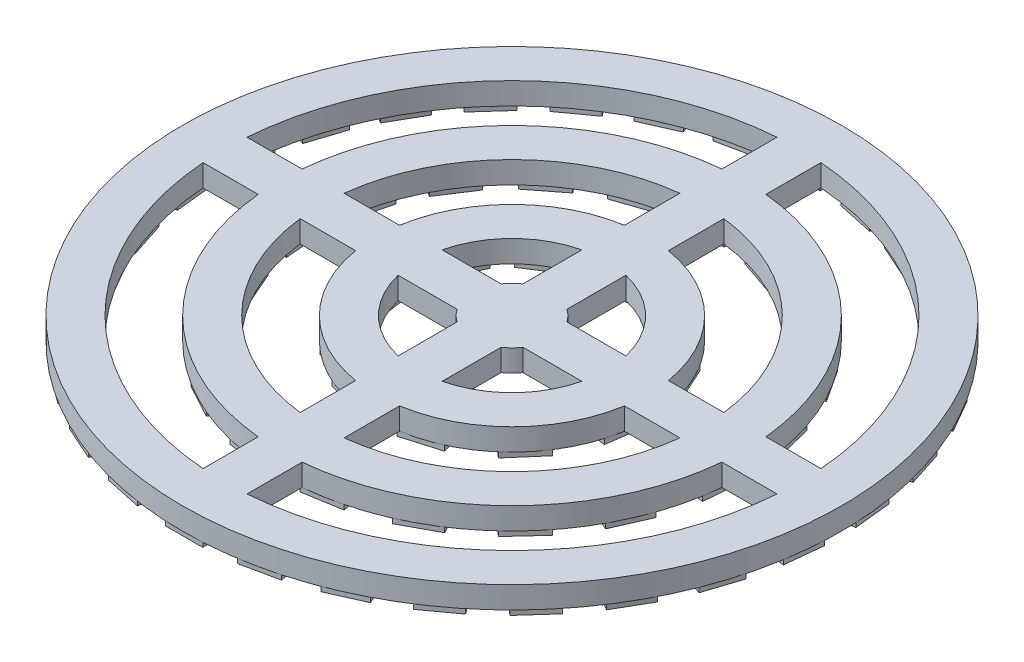
from build123d import *

# Parameters (mm, degrees)
SKETCH1_R           = 30
BOSS_EXTRUDE1_DEPTH = 2
CUT_EXTRUDE1_DEPTH  = 2
SKETCH3_W           = 3.4
SKETCH3_H           = 3.5
SKETCH3_W_2         = 3.5
BOSS_EXTRUDE2_DEPTH = 0.5


with BuildPart() as part:
    # Sketch1 → Boss-Extrude1 (new body)
    with BuildSketch(Plane(origin=(0, 0, 0), x_dir=(1, 0, 0), z_dir=(0, 1, 0))):
        Circle(SKETCH1_R)
    extrude(amount=BOSS_EXTRUDE1_DEPTH)

    # Sketch2 → Cut-Extrude1 (cut)
    with BuildSketch(Plane(origin=(0, 2, 0), x_dir=(1, 0, 0), z_dir=(0, 1, 0))):
        with BuildLine():
            Line((-21.105449533, -2), (-26.123552591, -2))
            ThreePointArc((-26.123552591, -2), (-18.526197667, -18.526197667), (-2, -26.123552591))
            Line((-2, -26.123552591), (-2, -21.105449533))
            ThreePointArc((-2, -21.105449533), (-14.990663761, -14.990663761), (-21.105449533, -2))
        make_face()
        with BuildLine():
            ThreePointArc((-2, 26.123552591), (-18.526197667, 18.526197667), (-26.123552591, 2))
            Line((-26.123552591, 2), (-21.105449533, 2))
            ThreePointArc((-21.105449533, 2), (-14.990663761, 14.990663761), (-2, 21.105449533))
            Line((-2, 21.105449533), (-2, 26.123552591))
        make_face()
        with BuildLine():
            ThreePointArc((26.123552591, 2), (18.526197667, 18.526197667), (2, 26.123552591))
            Line((2, 26.123552591), (2, 21.105449533))
            ThreePointArc((2, 21.105449533), (14.990663761, 14.990663761), (21.105449533, 2))
            Line((21.105449533, 2), (26.123552591, 2))
        make_face()
        with BuildLine():
            Line((2, -21.105449533), (2, -26.123552591))
            ThreePointArc((2, -26.123552591), (18.526197667, -18.526197667), (26.123552591, -2))
            Line((26.123552591, -2), (21.105449533, -2))
            ThreePointArc((21.105449533, -2), (14.990663761, -14.990663761), (2, -21.105449533))
        make_face()
        with BuildLine():
            Line((2, -12.237646833), (2, -17.284675293))
            ThreePointArc((2, -17.284675293), (12.303657993, -12.303657993), (17.284675293, -2))
            Line((17.284675293, -2), (12.237646833, -2))
            ThreePointArc((12.237646833, -2), (8.768124087, -8.768124087), (2, -12.237646833))
        make_face()
        with BuildLine():
            ThreePointArc((17.284675293, 2), (12.303657993, 12.303657993), (2, 17.284675293))
            Line((2, 17.284675293), (2, 12.237646833))
            ThreePointArc((2, 12.237646833), (8.768124087, 8.768124087), (12.237646833, 2))
            Line((12.237646833, 2), (17.284675293, 2))
        make_face()
        with BuildLine():
            ThreePointArc((-2, 17.284675293), (-12.303657993, 12.303657993), (-17.284675293, 2))
            Line((-17.284675293, 2), (-12.237646833, 2))
            ThreePointArc((-12.237646833, 2), (-8.768124087, 8.768124087), (-2, 12.237646833))
            Line((-2, 12.237646833), (-2, 17.284675293))
        make_face()
        with BuildLine():
            Line((-12.237646833, -2), (-17.284675293, -2))
            ThreePointArc((-17.284675293, -2), (-12.303657993, -12.303657993), (-2, -17.284675293))
            Line((-2, -17.284675293), (-2, -12.237646833))
            ThreePointArc((-2, -12.237646833), (-8.768124087, -8.768124087), (-12.237646833, -2))
        make_face()
        with BuildLine():
            Line((-2.993325909, -2), (-8.364209467, -2))
            ThreePointArc((-8.364209467, -2), (-6.081118318, -6.081118318), (-2, -8.364209467))
            Line((-2, -8.364209467), (-2, -2.993325909))
            ThreePointArc((-2, -2.993325909), (-2.545584412, -2.545584412), (-2.993325909, -2))
        make_face()
        with BuildLine():
            ThreePointArc((-2, 8.364209467), (-6.081118318, 6.081118318), (-8.364209467, 2))
            Line((-8.364209467, 2), (-2.993325909, 2))
            ThreePointArc((-2.993325909, 2), (-2.545584412, 2.545584412), (-2, 2.993325909))
            Line((-2, 2.993325909), (-2, 8.364209467))
        make_face()
        with BuildLine():
            ThreePointArc((8.364209467, 2), (6.081118318, 6.081118318), (2, 8.364209467))
            Line((2, 8.364209467), (2, 2.993325909))
            ThreePointArc((2, 2.993325909), (2.545584412, 2.545584412), (2.993325909, 2))
            Line((2.993325909, 2), (8.364209467, 2))
        make_face()
        with BuildLine():
            Line((2, -2.993325909), (2, -8.364209467))
            ThreePointArc((2, -8.364209467), (6.081118318, -6.081118318), (8.364209467, -2))
            Line((8.364209467, -2), (2.993325909, -2))
            ThreePointArc((2.993325909, -2), (2.545584412, -2.545584412), (2, -2.993325909))
        make_face()
    extrude(amount=-CUT_EXTRUDE1_DEPTH, mode=Mode.SUBTRACT)

    # Sketch3 → Boss-Extrude2 (add)
    with BuildSketch(Plane(origin=(0, 0, 0), x_dir=(-1, 0, 0), z_dir=(0, -1, 0))):
        with Locations((0, 28.1)):
            Rectangle(SKETCH3_W, SKETCH3_H)
        Polygon((7.141323974, 25.420739405), (7.869014892, 28.844256008), (4.54331305, 29.551155756), (3.815622132, 26.127639154), align=None)
        Polygon((12.270537823, 23.380470516), (13.694116074, 26.577879617), (10.588061518, 27.960784204), (9.164483267, 24.763375102), align=None)
        Polygon((16.863470288, 20.318362873), (18.920718671, 23.149922353), (16.17006089, 25.148392211), (14.112812507, 22.316832731), align=None)
        Polygon((20.719388182, 16.368245274), (23.320395071, 18.710202397), (21.04535101, 21.236894803), (18.444344121, 18.894937681), align=None)
        Polygon((23.66976939, 11.702756814), (26.700858303, 13.452756814), (25.000858303, 16.397243186), (21.96976939, 14.647243186), align=None)
        Polygon((25.585668095, 6.525801724), (28.914365902, 7.607361204), (27.863708121, 10.84095336), (24.535010314, 9.759393879), align=None)
        Polygon((26.383350331, 1.063637785), (29.864176964, 1.429487406), (29.508780189, 4.810861851), (26.027953555, 4.445012229), align=None)
        Polygon((26.027953555, -4.445012229), (29.508780189, -4.810861851), (29.864176964, -1.429487406), (26.383350331, -1.063637785), align=None)
        Polygon((24.535010314, -9.759393879), (27.863708121, -10.84095336), (28.914365902, -7.607361204), (25.585668095, -6.525801724), align=None)
        Polygon((21.96976939, -14.647243186), (25.000858303, -16.397243186), (26.700858303, -13.452756814), (23.66976939, -11.702756814), align=None)
        Polygon((18.444344121, -18.894937681), (21.04535101, -21.236894803), (23.320395071, -18.710202396), (20.719388182, -16.368245274), align=None)
        Polygon((14.112812507, -22.316832731), (16.170060891, -25.148392211), (18.920718671, -23.149922353), (16.863470288, -20.318362873), align=None)
        Polygon((9.164483267, -24.763375102), (10.588061518, -27.960784204), (13.694116074, -26.577879617), (12.270537823, -23.380470516), align=None)
        Polygon((3.815622132, -26.127639154), (4.54331305, -29.551155756), (7.869014892, -28.844256008), (7.141323974, -25.420739405), align=None)
        with Locations((0, -28.1)):
            Rectangle(SKETCH3_W, SKETCH3_H)
        Polygon((-7.141323974, -25.420739405), (-7.869014892, -28.844256008), (-4.54331305, -29.551155756), (-3.815622132, -26.127639154), align=None)
        Polygon((-12.270537823, -23.380470516), (-13.694116074, -26.577879617), (-10.588061518, -27.960784204), (-9.164483267, -24.763375102), align=None)
        Polygon((5.179743654, 20.477677009), (8.490104, 19.341228867), (7.353655858, 16.030868521), (4.043295512, 17.167316663), align=None)
        with Locations((0, 19.3)):
            Rectangle(SKETCH3_W_2, SKETCH3_H)
        Polygon((11.548181711, 17.68627997), (14.310173494, 15.536535476), (12.160428999, 12.774543693), (9.398437216, 14.924288187), align=None)
        Polygon((16.665195091, 12.978300065), (18.579513644, 10.048217392), (15.64943097, 8.133898838), (13.735112417, 11.063981512), align=None)
        Polygon((19.976275996, 6.86391997), (20.835475201, 3.471019039), (17.44257427, 2.611819834), (16.583375065, 6.004720765), align=None)
        Polygon((21.122617432, 0.005727641), (20.833589723, -3.482318085), (17.345543998, -3.193290376), (17.634571707, 0.29475535), align=None)
        Polygon((19.979995519, -6.853085367), (18.574061533, -10.058292011), (15.36885489, -8.652358024), (16.774788876, -5.447151381), align=None)
        Polygon((16.67223107, -12.969260239), (14.301745569, -15.544293926), (11.726711882, -13.173808426), (14.097197383, -10.598774738), align=None)
        Polygon((11.557771688, -17.680014525), (8.479613559, -19.345830401), (6.813797683, -16.267672271), (9.891955812, -14.601856396), align=None)
        Polygon((5.190848406, -20.474864904), (1.738583844, -21.05094597), (1.162502778, -17.598681408), (4.61476734, -17.022600342), align=None)
        Polygon((-1.738583844, -21.05094597), (-5.190848406, -20.474864904), (-4.61476734, -17.022600342), (-1.162502778, -17.598681408), align=None)
        Polygon((-8.479613559, -19.345830401), (-11.557771688, -17.680014525), (-9.891955812, -14.601856396), (-6.813797683, -16.267672271), align=None)
        Polygon((5.150656331, 11.251477208), (8.095043696, 9.359234347), (6.202800835, 6.414846982), (3.25841347, 8.307089843), align=None)
        with Locations((0, 10.5)):
            Rectangle(SKETCH3_W_2, SKETCH3_H)
        Polygon((10.41601567, 6.680689901), (11.869968216, 3.496977917), (8.686256232, 2.043025372), (7.232303687, 5.226737356), align=None)
        Polygon((12.37436363, -0.011169246), (11.876261696, -3.475544292), (8.411886649, -2.977442358), (8.909988583, 0.486932688), align=None)
        Polygon((10.40393857, -6.699482236), (8.111926001, -9.344605746), (5.466802491, -7.052593177), (7.75881506, -4.407469667), align=None)
        Polygon((5.130336525, -11.260756952), (1.772111117, -12.246820901), (0.786047169, -8.888595494), (4.144272576, -7.902531545), align=None)
        Polygon((-1.772111117, -12.246820901), (-5.130336525, -11.260756952), (-4.144272576, -7.902531545), (-0.786047169, -8.888595494), align=None)
        Polygon((-8.111926001, -9.344605746), (-10.40393857, -6.699482236), (-7.75881506, -4.407469667), (-5.466802491, -7.052593177), align=None)
        Rectangle(SKETCH3_W_2, SKETCH3_H)
        Polygon((-16.863470288, -20.318362873), (-18.920718671, -23.149922353), (-16.17006089, -25.148392211), (-14.112812507, -22.316832731), align=None)
        Polygon((-20.719388182, -16.368245274), (-23.320395071, -18.710202397), (-21.04535101, -21.236894803), (-18.444344121, -18.894937681), align=None)
        Polygon((-11.876261696, -3.475544292), (-12.37436363, -0.011169246), (-8.909988583, 0.486932688), (-8.411886649, -2.977442358), align=None)
        Polygon((-11.869968216, 3.496977917), (-10.41601567, 6.680689901), (-7.232303687, 5.226737356), (-8.686256232, 2.043025372), align=None)
        Polygon((-8.095043696, 9.359234347), (-5.150656331, 11.251477208), (-3.25841347, 8.307089843), (-6.202800835, 6.414846982), align=None)
        Polygon((-14.301745569, -15.544293926), (-16.67223107, -12.969260239), (-14.097197383, -10.598774738), (-11.726711882, -13.173808426), align=None)
        Polygon((-18.574061533, -10.058292011), (-19.979995519, -6.853085367), (-16.774788876, -5.447151381), (-15.36885489, -8.652358024), align=None)
        Polygon((-20.833589723, -3.482318085), (-21.122617432, 0.005727641), (-17.634571707, 0.29475535), (-17.345543998, -3.193290376), align=None)
        Polygon((-20.835475201, 3.471019039), (-19.976275996, 6.86391997), (-16.583375065, 6.004720765), (-17.44257427, 2.611819834), align=None)
        Polygon((-18.579513644, 10.048217392), (-16.665195091, 12.978300065), (-13.735112417, 11.063981512), (-15.64943097, 8.133898838), align=None)
        Polygon((-14.310173494, 15.536535476), (-11.548181711, 17.68627997), (-9.398437216, 14.924288187), (-12.160428999, 12.774543693), align=None)
        Polygon((-8.490104, 19.341228867), (-5.179743654, 20.477677009), (-4.043295512, 17.167316663), (-7.353655858, 16.030868521), align=None)
        Polygon((-23.66976939, -11.702756814), (-26.700858303, -13.452756814), (-25.000858303, -16.397243186), (-21.96976939, -14.647243186), align=None)
        Polygon((-25.585668095, -6.525801724), (-28.914365902, -7.607361204), (-27.863708121, -10.84095336), (-24.535010314, -9.759393879), align=None)
        Polygon((-26.38335033, -1.063637785), (-29.864176964, -1.429487406), (-29.508780189, -4.810861851), (-26.027953555, -4.445012229), align=None)
        Polygon((-26.027953555, 4.445012229), (-29.508780189, 4.810861851), (-29.864176964, 1.429487406), (-26.383350331, 1.063637785), align=None)
        Polygon((-24.535010314, 9.759393879), (-27.863708121, 10.84095336), (-28.914365902, 7.607361204), (-25.585668095, 6.525801724), align=None)
        Polygon((-21.96976939, 14.647243186), (-25.000858303, 16.397243186), (-26.700858303, 13.452756814), (-23.66976939, 11.702756814), align=None)
        Polygon((-18.444344121, 18.894937681), (-21.04535101, 21.236894803), (-23.320395071, 18.710202396), (-20.719388182, 16.368245274), align=None)
        Polygon((-14.112812507, 22.316832731), (-16.17006089, 25.148392211), (-18.920718671, 23.149922353), (-16.863470288, 20.318362873), align=None)
        Polygon((-9.164483267, 24.763375102), (-10.588061518, 27.960784204), (-13.694116074, 26.577879617), (-12.270537823, 23.380470516), align=None)
        Polygon((-3.815622132, 26.127639154), (-4.54331305, 29.551155756), (-7.869014892, 28.844256008), (-7.141323974, 25.420739405), align=None)
    extrude(amount=BOSS_EXTRUDE2_DEPTH)


solid = part.part
